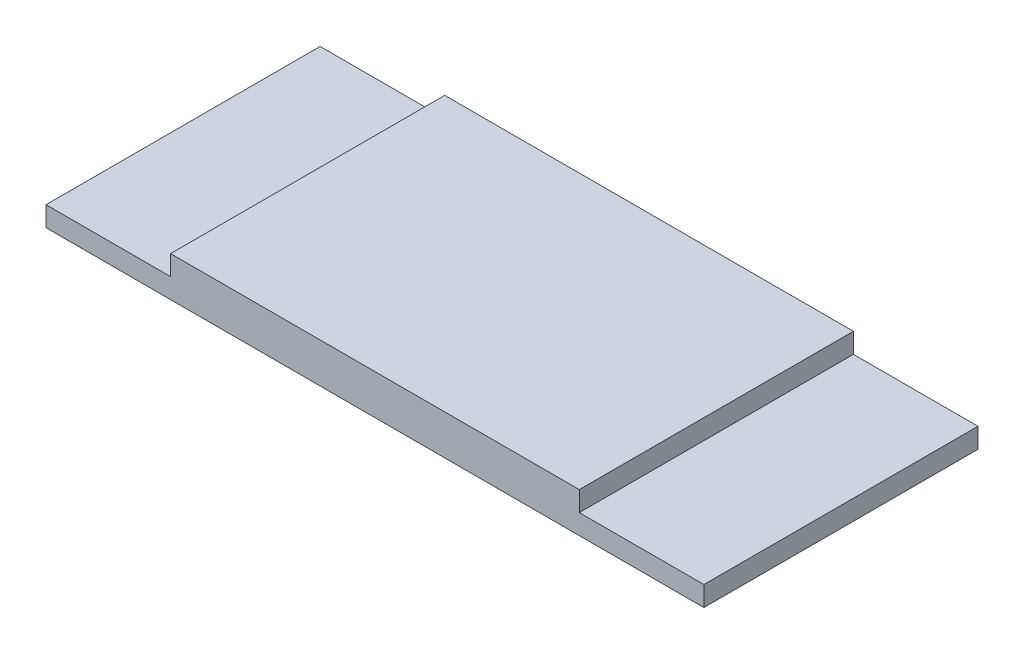
from build123d import *

# Parameters (mm, degrees)
SKETCH_1_W      = 16.4
SKETCH_1_H      = 11
EXTRUDE_1_DEPTH = 0.8
SKETCH_3_W      = 26.4
SKETCH_3_H      = 11
EXTRUDE_2_DEPTH = 0.8


with BuildPart() as part:
    # Эскиз1 → Бобышка-Вытянуть1 (new body)
    with BuildSketch(Plane(origin=(0, 0, 0), x_dir=(1, 0, 0), z_dir=(0, 1, 0))):
        Rectangle(SKETCH_1_W, SKETCH_1_H)
    extrude(amount=EXTRUDE_1_DEPTH)

    # Эскиз3 → Бобышка-Вытянуть2 (add)
    with BuildSketch(Plane.XZ):
        Rectangle(SKETCH_3_W, SKETCH_3_H)
    extrude(amount=EXTRUDE_2_DEPTH)


solid = part.part
